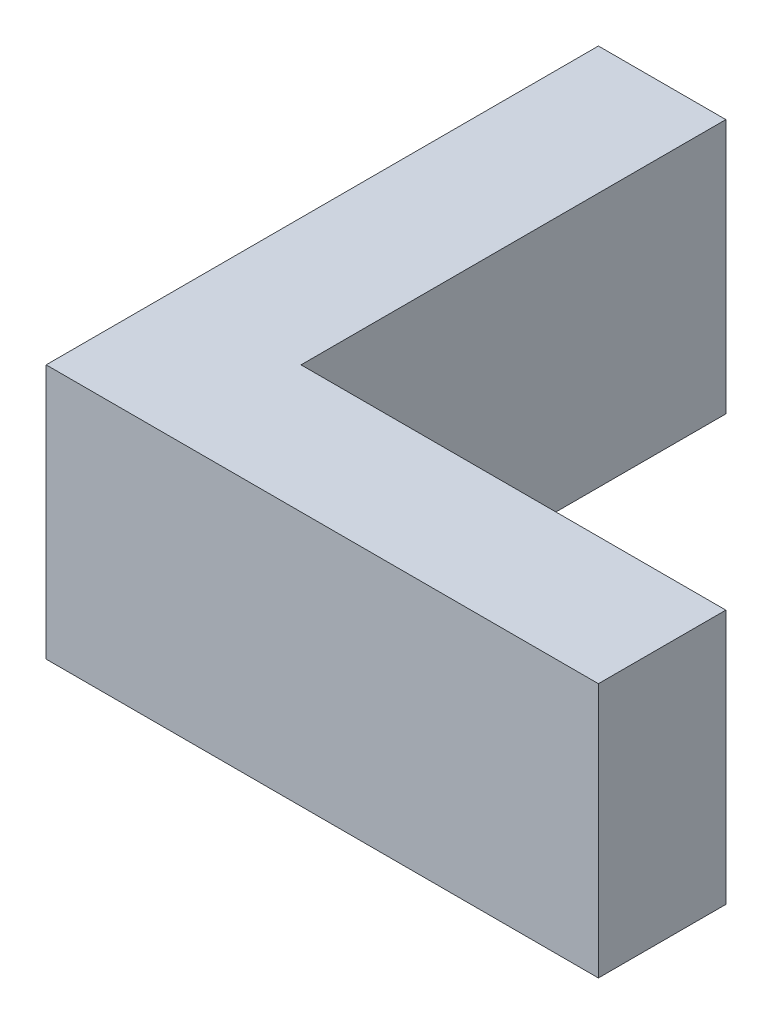
from build123d import *

# Parameters (mm, degrees)
SALIENTE_EXTRUIR1_DEPTH = 12


with BuildPart() as part:
    # Croquis1 → Saliente-Extruir1 (new body)
    with BuildSketch(Plane(origin=(0, 0, 0), x_dir=(1, 0, 0), z_dir=(0, 1, 0))):
        Polygon((0, 0), (0, 20), (-6, 20), (-6, -6), (20, -6), (20, 0), align=None)
    extrude(amount=SALIENTE_EXTRUIR1_DEPTH)


solid = part.part
